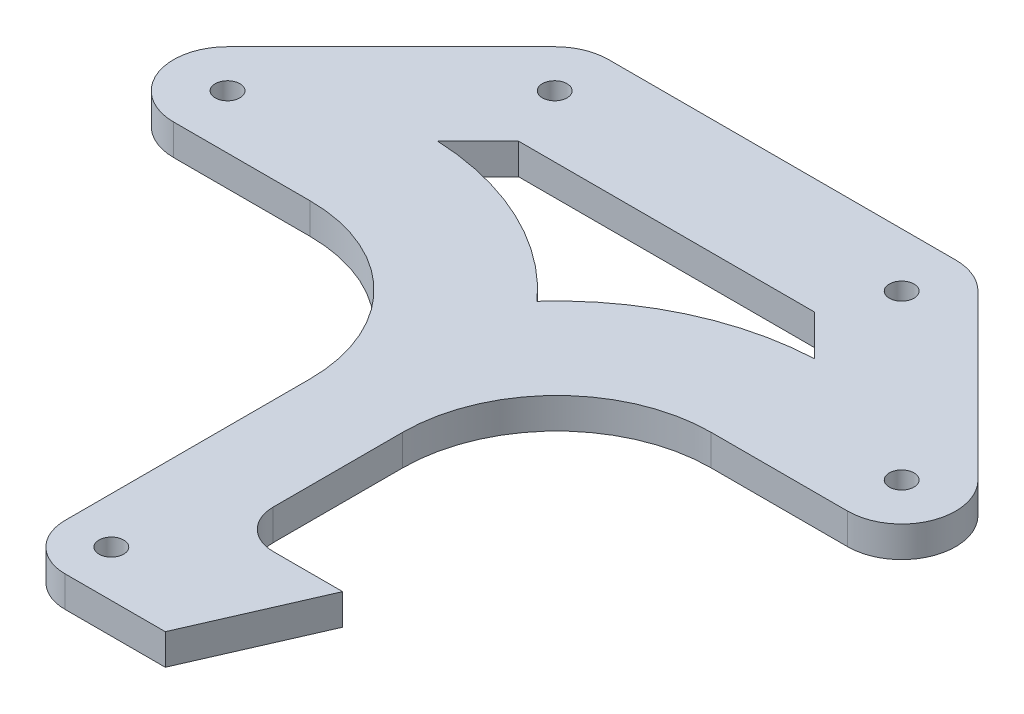
from build123d import *

# Parameters (mm, degrees)
SKETCH1_R           = 3
SKETCH1_R_2         = 1.6
BOSS_EXTRUDE1_DEPTH = 4


with BuildPart() as part:
    # Sketch1 → Boss-Extrude1 (new body)
    with BuildSketch(Plane(origin=(0, 0, 0), x_dir=(1, 0, 0), z_dir=(0, 1, 0))):
        with BuildLine():
            Line((11, 10), (20, 10))
            Line((20, 10), (13, -6))
            Line((13, -6), (0, -6))
            ThreePointArc((0, -6), (-4.242640687, -4.242640687), (-6, 0))
            Line((-6, 0), (-6, 31.786796564))
            ThreePointArc((-6, 31.786796564), (-11.857864376, 45.928932188), (-26, 51.786796564))
            Line((-26, 51.786796564), (-43.713203436, 51.786796564))
            ThreePointArc((-43.713203436, 51.786796564), (-50.180360163, 56.108012538), (-48.662950904, 63.736544033))
            Line((-48.662950904, 63.736544033), (-27.449747468, 84.949747468))
            ThreePointArc((-27.449747468, 84.949747468), (-25.178784027, 86.467156728), (-22.5, 87))
            Line((-22.5, 87), (22.5, 87))
            ThreePointArc((22.5, 87), (25.178784027, 86.467156728), (27.449747468, 84.949747468))
            Line((27.449747468, 84.949747468), (48.662950904, 63.736544033))
            ThreePointArc((48.662950904, 63.736544033), (50.180360163, 56.108012538), (43.713203436, 51.786796564))
            Line((43.713203436, 51.786796564), (26, 51.786796564))
            ThreePointArc((26, 51.786796564), (11.857864376, 45.928932188), (6, 31.786796564))
            Line((6, 31.786796564), (6, 15))
            ThreePointArc((6, 15), (7.464466094, 11.464466094), (11, 10))
        make_face()
        with Locations((-22.5, 80)):
            Circle(SKETCH1_R, mode=Mode.SUBTRACT)
        with Locations((22.5, 80)):
            Circle(SKETCH1_R, mode=Mode.SUBTRACT)
        Circle(SKETCH1_R, mode=Mode.SUBTRACT)
        with Locations((-43.713203436, 58.786796564)):
            Circle(SKETCH1_R, mode=Mode.SUBTRACT)
        with Locations((43.713203436, 58.786796564)):
            Circle(SKETCH1_R, mode=Mode.SUBTRACT)
        with BuildLine():
            ThreePointArc((24.434522737, 66.751768764), (11.059335348, 63.437650262), (0, 55.217545592))
            ThreePointArc((0, 55.217545592), (-11.059335348, 63.437650262), (-24.434522737, 66.751768764))
            Line((-24.434522737, 66.751768764), (-19.186291501, 72))
            Line((-19.186291501, 72), (19.186291501, 72))
            Line((19.186291501, 72), (24.434522737, 66.751768764))
        make_face(mode=Mode.SUBTRACT)
        Circle(SKETCH1_R)
        with Locations(Location((0, 0, 0), (0, 0, 270))):
            Circle(SKETCH1_R_2, mode=Mode.SUBTRACT)
        with Locations((43.713203436, 58.786796564)):
            Circle(SKETCH1_R)
        with Locations(Location((43.713203436, 58.786796564, 0), (0, 0, 270))):
            Circle(SKETCH1_R_2, mode=Mode.SUBTRACT)
        with Locations((22.5, 80)):
            Circle(SKETCH1_R)
        with Locations(Location((22.5, 80, 0), (0, 0, 270))):
            Circle(SKETCH1_R_2, mode=Mode.SUBTRACT)
        with Locations((-22.5, 80)):
            Circle(SKETCH1_R)
        with Locations(Location((-22.5, 80, 0), (0, 0, 270))):
            Circle(SKETCH1_R_2, mode=Mode.SUBTRACT)
        with Locations((-43.713203436, 58.786796564)):
            Circle(SKETCH1_R)
        with Locations(Location((-43.713203436, 58.786796564, 0), (0, 0, 270))):
            Circle(SKETCH1_R_2, mode=Mode.SUBTRACT)
    extrude(amount=BOSS_EXTRUDE1_DEPTH)


solid = part.part
